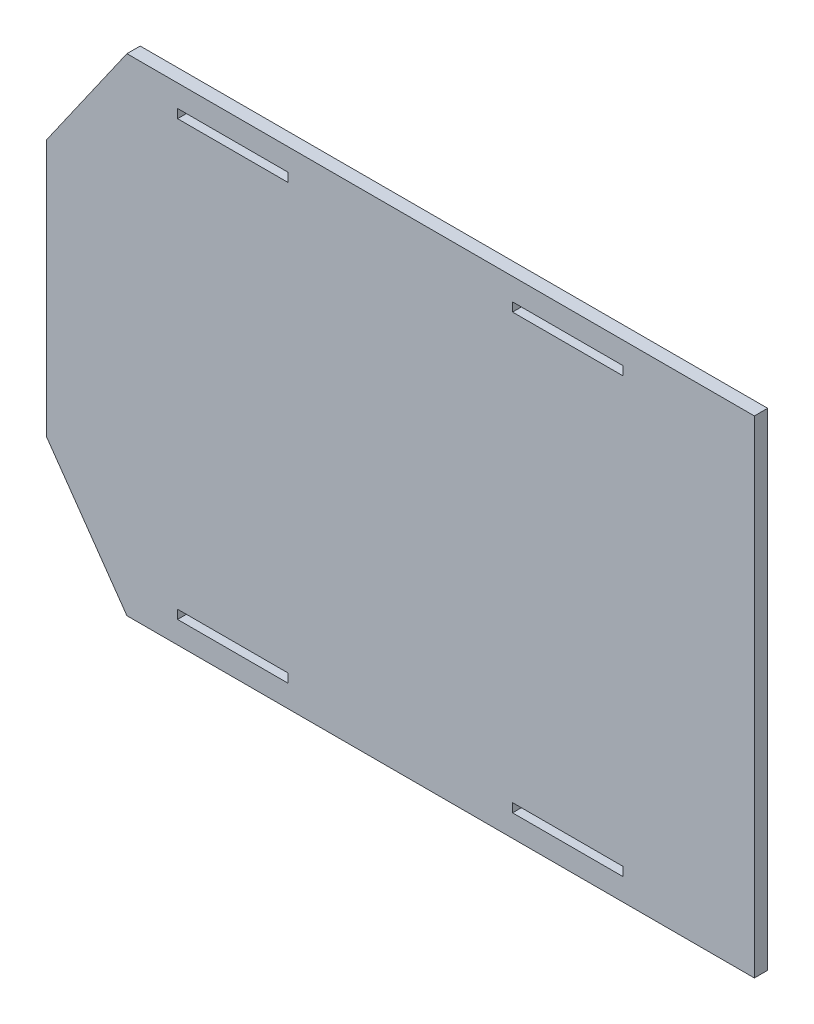
from build123d import *

# Parameters (mm, degrees)
SKIZZE1_W                       = 320
SKIZZE1_H                       = 220
AUFSATZ_LINEAR_AUSTRAGEN1_DEPTH = 6
SKIZZE2_W                       = 50
SKIZZE2_H                       = 4
SCHNITT_LINEAR_AUSTRAGEN1_DEPTH = 6
SPIEGELN2_COPY_1_SKETCH_W       = 50
SPIEGELN2_COPY_1_SKETCH_H       = 4
SPIEGELN2_COPY_1_DEPTH          = 6
SCHNITT_LINEAR_AUSTRAGEN2_DEPTH = 6


with BuildPart() as part:
    # Skizze1 → Aufsatz-Linear austragen1 (new body)
    with BuildSketch(Plane.XY):
        with Locations((160, 110)):
            Rectangle(SKIZZE1_W, SKIZZE1_H)
    extrude(amount=AUFSATZ_LINEAR_AUSTRAGEN1_DEPTH)

    # Skizze2 → Schnitt-Linear austragen1 (cut)
    with BuildSketch(Plane.XY.offset(6)):
        with Locations((84.3, 208)):
            Rectangle(SKIZZE2_W, SKIZZE2_H)
    schnitt_linear_austragen1 = extrude(amount=-SCHNITT_LINEAR_AUSTRAGEN1_DEPTH, mode=Mode.SUBTRACT)

    # Spiegeln1: Schnitt-Linear austragen1 across plane
    add(schnitt_linear_austragen1.mirror(Plane(origin=(160, 0, 0), x_dir=(0, 0, 1), z_dir=(1, 0, 0))), mode=Mode.SUBTRACT)

    # Spiegeln2: Schnitt-Linear austragen1 across plane
    add(schnitt_linear_austragen1.mirror(Plane.ZX.offset(110)), mode=Mode.SUBTRACT)

    # Spiegeln2 copy 1 sketch → Spiegeln2 copy 1 (cut)
    with BuildSketch(Plane(origin=(320, 220, 6), x_dir=(-1, 0, 0), z_dir=(0, 0, 1))):
        with Locations((84.3, 208)):
            Rectangle(SPIEGELN2_COPY_1_SKETCH_W, SPIEGELN2_COPY_1_SKETCH_H)
    extrude(amount=-SPIEGELN2_COPY_1_DEPTH, mode=Mode.SUBTRACT)

    # Skizze3 → Schnitt-Linear austragen2 (cut)
    with BuildSketch(Plane.XY.offset(6)):
        Polygon((0, 52), (36.410791987, 0), (0, 0), align=None)
    schnitt_linear_austragen2 = extrude(amount=-SCHNITT_LINEAR_AUSTRAGEN2_DEPTH, mode=Mode.SUBTRACT)

    # Spiegeln3: Schnitt-Linear austragen2 across plane
    add(schnitt_linear_austragen2.mirror(Plane.ZX.offset(110)), mode=Mode.SUBTRACT)


solid = part.part
